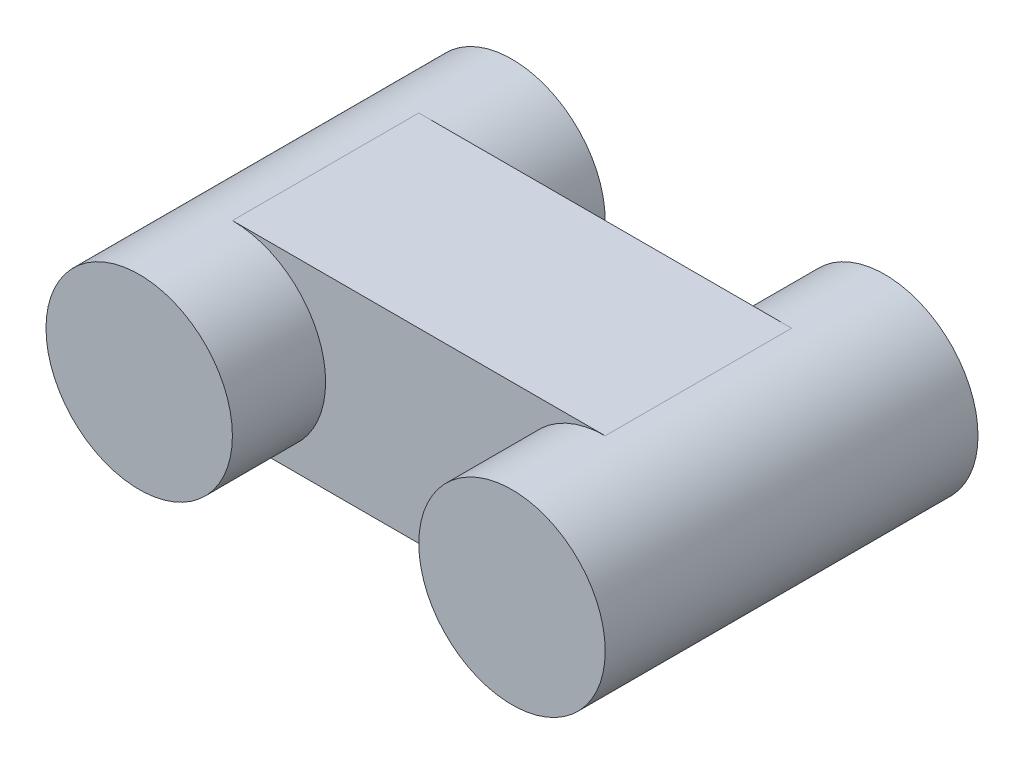
from build123d import *

# Parameters (mm, degrees)
EXTRUDE_3_DEPTH      = 2
EXTRUDE_4_DEPTH      = 1
EXTRUDE_4_DEPTH_BACK = 3


with BuildPart() as part:
    # Sketch 1 → Extrude 3 (new body)
    with BuildSketch(Plane.XY):
        with BuildLine():
            ThreePointArc((0, 1), (-1, 0), (0, -1))
            Line((0, -1), (0, 1))
        make_face()
        with BuildLine():
            Line((0, 1), (0, -1))
            ThreePointArc((0, -1), (0.707106781, -0.707106781), (1, 0))
            ThreePointArc((1, 0), (0.707106781, 0.707106781), (0, 1))
        make_face()
        with BuildLine():
            ThreePointArc((0, 1), (-1, 0), (0, -1))
            Line((0, -1), (0, 1))
        make_face()
        with BuildLine():
            Line((0, 1), (0, -1))
            ThreePointArc((0, -1), (0.707106781, -0.707106781), (1, 0))
            ThreePointArc((1, 0), (0.707106781, 0.707106781), (0, 1))
        make_face()
        with BuildLine():
            ThreePointArc((1, 0), (0.707106781, -0.707106781), (0, -1))
            Line((0, -1), (4, -1))
            ThreePointArc((4, -1), (3, 0), (4, 1))
            Line((4, 1), (0, 1))
            ThreePointArc((0, 1), (0.707106781, 0.707106781), (1, 0))
        make_face()
        with BuildLine():
            ThreePointArc((4, 1), (3, 0), (4, -1))
            Line((4, -1), (4, 1))
        make_face()
        with BuildLine():
            Line((4, 1), (4, -1))
            ThreePointArc((4, -1), (4.707106781, -0.707106781), (5, 0))
            ThreePointArc((5, 0), (4.707106781, 0.707106781), (4, 1))
        make_face()
        with BuildLine():
            ThreePointArc((4, 1), (3, 0), (4, -1))
            Line((4, -1), (4, 1))
        make_face()
        with BuildLine():
            Line((4, 1), (4, -1))
            ThreePointArc((4, -1), (4.707106781, -0.707106781), (5, 0))
            ThreePointArc((5, 0), (4.707106781, 0.707106781), (4, 1))
        make_face()
    extrude(amount=-EXTRUDE_3_DEPTH)

    # Sketch 1_7 → Extrude 4 (add, two sides)
    with BuildSketch(Plane.XY) as extrude_4_sk:
        with BuildLine():
            ThreePointArc((0, 1), (-1, 0), (0, -1))
            Line((0, -1), (0, 1))
        make_face()
        with BuildLine():
            Line((0, 1), (0, -1))
            ThreePointArc((0, -1), (0.707106781, -0.707106781), (1, 0))
            ThreePointArc((1, 0), (0.707106781, 0.707106781), (0, 1))
        make_face()
        with BuildLine():
            ThreePointArc((0, 1), (-1, 0), (0, -1))
            Line((0, -1), (0, 1))
        make_face()
        with BuildLine():
            Line((0, 1), (0, -1))
            ThreePointArc((0, -1), (0.707106781, -0.707106781), (1, 0))
            ThreePointArc((1, 0), (0.707106781, 0.707106781), (0, 1))
        make_face()
        with BuildLine():
            ThreePointArc((4, 1), (3, 0), (4, -1))
            Line((4, -1), (4, 1))
        make_face()
        with BuildLine():
            Line((4, 1), (4, -1))
            ThreePointArc((4, -1), (4.707106781, -0.707106781), (5, 0))
            ThreePointArc((5, 0), (4.707106781, 0.707106781), (4, 1))
        make_face()
        with BuildLine():
            ThreePointArc((4, 1), (3, 0), (4, -1))
            Line((4, -1), (4, 1))
        make_face()
        with BuildLine():
            Line((4, 1), (4, -1))
            ThreePointArc((4, -1), (4.707106781, -0.707106781), (5, 0))
            ThreePointArc((5, 0), (4.707106781, 0.707106781), (4, 1))
        make_face()
    extrude(amount=EXTRUDE_4_DEPTH)
    extrude(extrude_4_sk.sketch, amount=-EXTRUDE_4_DEPTH_BACK)


solid = part.part
